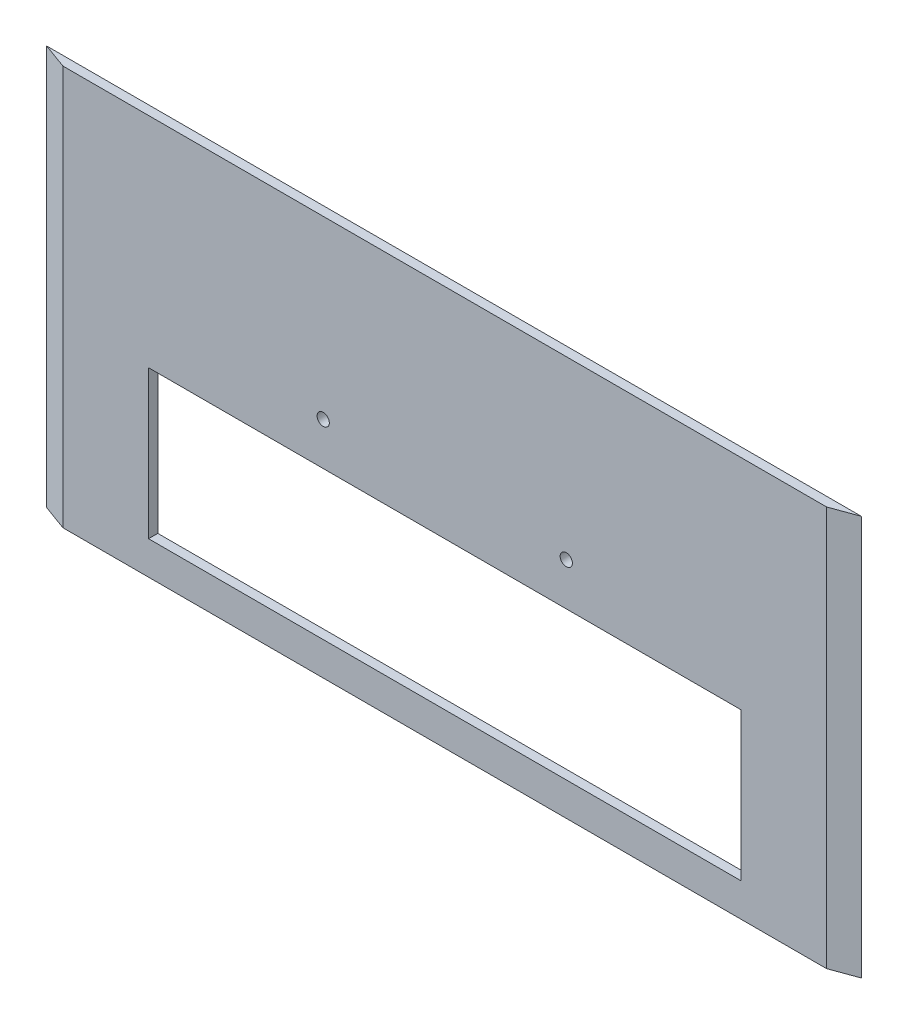
from build123d import *

# Parameters (mm, degrees)
SKETCH1_W           = 175
SKETCH1_H           = 63
BOSS_EXTRUDE1_DEPTH = 2.5
SKETCH2_W           = 160
SKETCH2_H           = 40
CUT_EXTRUDE1_DEPTH  = 2.5
SKETCH5_W           = 175
SKETCH5_H           = 45
BOSS_EXTRUDE3_DEPTH = 2.5
BOSS_EXTRUDE2_DEPTH = 108
SKETCH4_R           = 1.65
CUT_EXTRUDE2_DEPTH  = 3.5


with BuildPart() as part:
    # Sketch1 → Boss-Extrude1 (new body)
    with BuildSketch(Plane.XY):
        Rectangle(SKETCH1_W, SKETCH1_H)
    extrude(amount=BOSS_EXTRUDE1_DEPTH)

    # Sketch2 → Cut-Extrude1 (cut)
    with BuildSketch(Plane.XY.offset(2.5)):
        with Locations((0, -2.5)):
            Rectangle(SKETCH2_W, SKETCH2_H)
    extrude(amount=-CUT_EXTRUDE1_DEPTH, mode=Mode.SUBTRACT)

    # Sketch5 → Boss-Extrude3 (add)
    with BuildSketch(Plane.XY.offset(2.5)):
        with Locations((0, 54)):
            Rectangle(SKETCH5_W, SKETCH5_H)
    extrude(amount=-BOSS_EXTRUDE3_DEPTH)

    # Sketch3 → Boss-Extrude2 (add)
    with BuildSketch(Plane(origin=(0, -31.5, 0), x_dir=(1, 0, 0), z_dir=(0, 1, 0))):
        Polygon((-87.5, -2.5), (-103.131306451, -2.5), (-110, 0), (-87.5, 0), align=None)
    boss_extrude2 = extrude(amount=BOSS_EXTRUDE2_DEPTH)

    # Mirror1: Boss-Extrude2 across plane
    add(boss_extrude2.mirror(Plane(origin=(0, 0, 0), x_dir=(0, 0, 1), z_dir=(1, 0, 0))))

    # Sketch4 → Cut-Extrude2 (cut, through all)
    with BuildSketch(Plane(origin=(0, 0, 0), x_dir=(-1, 0, 0), z_dir=(0, 0, -1))):
        with Locations((-32.825, 29)):
            Circle(SKETCH4_R)
    cut_extrude2 = extrude(amount=-CUT_EXTRUDE2_DEPTH, mode=Mode.SUBTRACT)

    # Mirror2: Cut-Extrude2 across plane
    add(cut_extrude2.mirror(Plane(origin=(0, 0, 0), x_dir=(0, 0, 1), z_dir=(1, 0, 0))), mode=Mode.SUBTRACT)


solid = part.part
